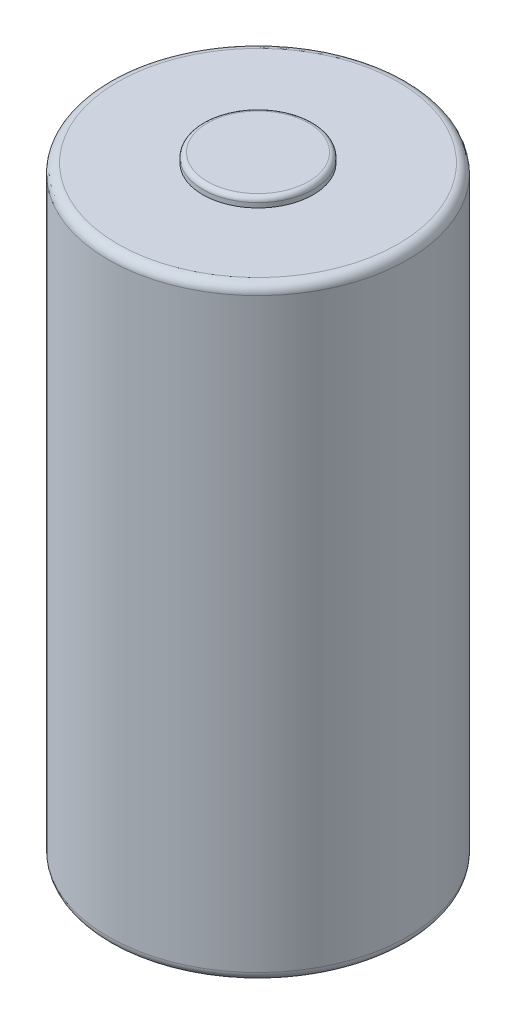
from build123d import *

# Parameters (mm, degrees)
SKETCH1_R           = 8.255
BOSS_EXTRUDE1_DEPTH = 33.3756
SKETCH2_R           = 3.048
BOSS_EXTRUDE2_DEPTH = 0.508
SKETCH3_R           = 5.08
BOSS_EXTRUDE3_DEPTH = 0.1016
FILLET1_R           = 0.508
FILLET2_R           = 0.254


with BuildPart() as part:
    # Sketch1 → Boss-Extrude1 (new body)
    with BuildSketch(Plane(origin=(0, 0, 0), x_dir=(1, 0, 0), z_dir=(0, 1, 0))):
        Circle(SKETCH1_R)
    extrude(amount=BOSS_EXTRUDE1_DEPTH)

    # Sketch2 → Boss-Extrude2 (add)
    with BuildSketch(Plane(origin=(0, 33.3756, 0), x_dir=(1, 0, 0), z_dir=(0, 1, 0))):
        Circle(SKETCH2_R)
    extrude(amount=BOSS_EXTRUDE2_DEPTH)

    # Sketch3 → Boss-Extrude3 (add)
    with BuildSketch(Plane.XZ):
        Circle(SKETCH3_R)
    extrude(amount=BOSS_EXTRUDE3_DEPTH)

    # Fillet1
    fillet1_edges = [part.edges().sort_by_distance(p)[0] for p in [
        (-8.255, 0, 0),
        (-8.255, 33.3756, 0),
    ]]
    fillet(fillet1_edges, radius=FILLET1_R)

    # Fillet2
    fillet2_edges = [part.edges().sort_by_distance(p)[0] for p in [
        (-3.048, 33.8836, 0),
    ]]
    fillet(fillet2_edges, radius=FILLET2_R)


solid = part.part
